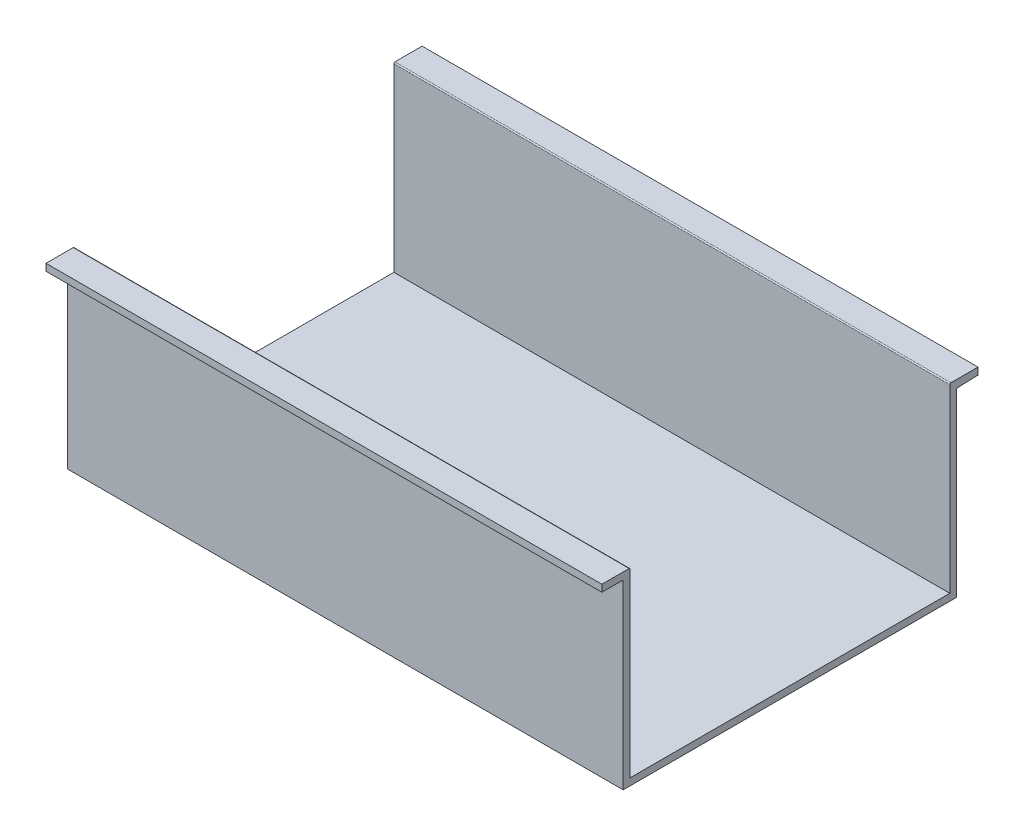
from build123d import *

# Parameters (mm, degrees)
BOSS_EXTRUDE1_DEPTH = 400


with BuildPart() as part:
    # Sketch1 → Boss-Extrude1 (new body)
    with BuildSketch(Plane(origin=(0, 0, 0), x_dir=(0, 0, -1), z_dir=(1, 0, 0))):
        with BuildLine():
            Line((5, -5), (5, -125.270799085))
            Line((5, -125.270799085), (235, -125.270799085))
            Line((235, -125.270799085), (235, -5))
            Line((235, -5), (235, 4.729200915))
            ThreePointArc((235, 4.729200915), (235.234314575, 5.29488634), (235.8, 5.529200915))
            Line((235.8, 5.529200915), (255.315878667, 5.529200915))
            Line((255.315878667, 5.529200915), (255.315878667, 0.529200915))
            Line((255.315878667, 0.529200915), (240.770883182, -0.000530044))
            ThreePointArc((240.770883182, -0.000530044), (240.224112227, -0.244704337), (240, -0.8))
            Line((240, -0.8), (240, -130.270799085))
            Line((240, -130.270799085), (0, -130.270799085))
            Line((0, -130.270799085), (0, -0.270799085))
            ThreePointArc((0, -0.270799085), (-0.234314575, 0.29488634), (-0.8, 0.529200915))
            Line((-0.8, 0.529200915), (-15.315878667, 0.529200915))
            Line((-15.315878667, 0.529200915), (-15.315878667, 5.529200915))
            Line((-15.315878667, 5.529200915), (4.2, 5.529200915))
            ThreePointArc((4.2, 5.529200915), (4.765685425, 5.29488634), (5, 4.729200915))
            Line((5, 4.729200915), (5, -5))
        make_face()
    extrude(amount=BOSS_EXTRUDE1_DEPTH)


solid = part.part
